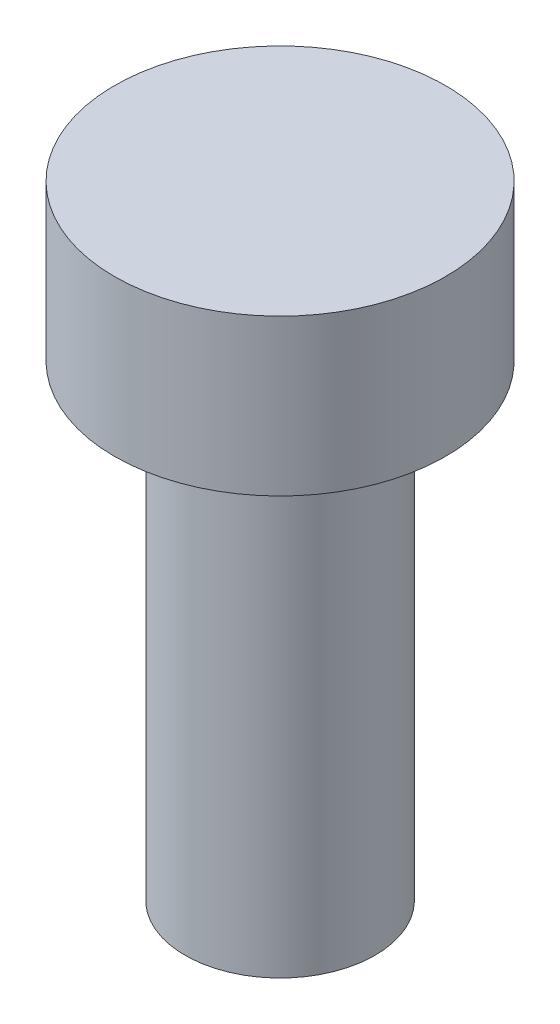
from build123d import *

# Parameters (mm, degrees)
SKETCH1_R           = 4.25
BOSS_EXTRUDE1_DEPTH = 4
SKETCH2_R           = 2.44
BOSS_EXTRUDE2_DEPTH = 12


with BuildPart() as part:
    # Sketch1 → Boss-Extrude1 (new body)
    with BuildSketch(Plane(origin=(0, 0, 0), x_dir=(1, 0, 0), z_dir=(0, 1, 0))):
        Circle(SKETCH1_R)
    extrude(amount=BOSS_EXTRUDE1_DEPTH)

    # Sketch2 → Boss-Extrude2 (add)
    with BuildSketch(Plane.XZ):
        Circle(SKETCH2_R)
    extrude(amount=BOSS_EXTRUDE2_DEPTH)


solid = part.part
